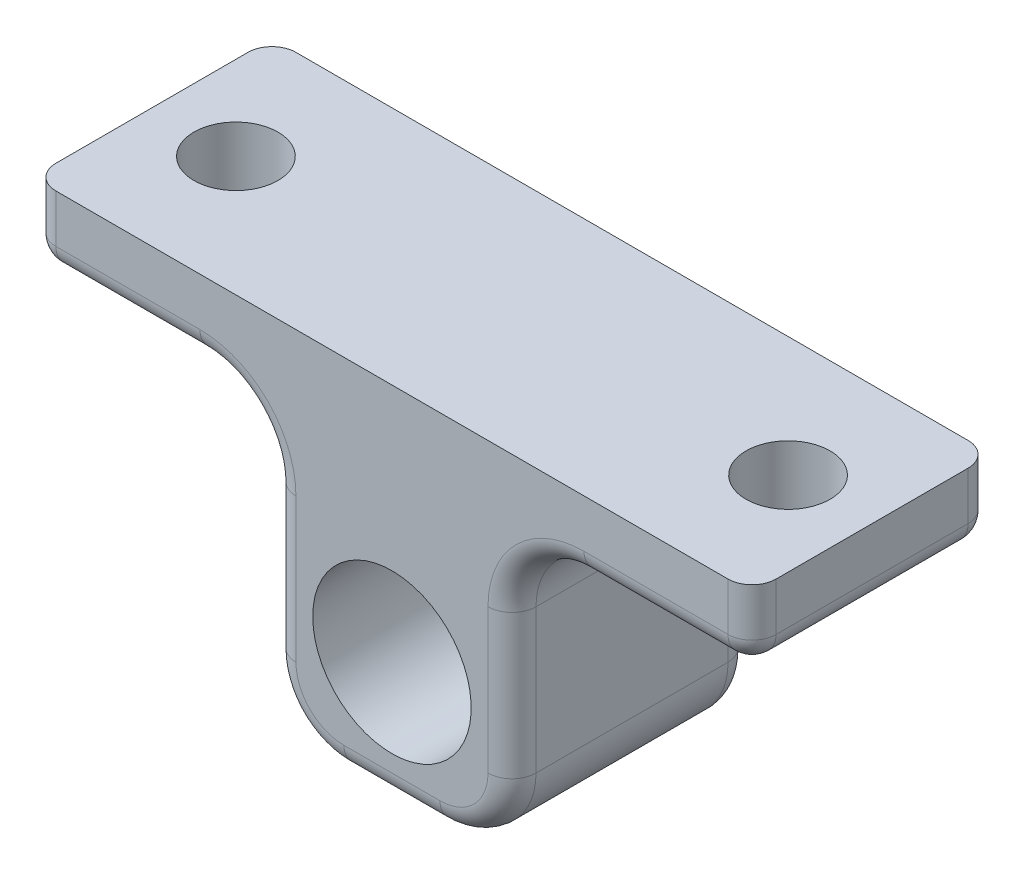
from build123d import *

# Parameters (mm, degrees)
SKETCH_1_W          = 10
SKETCH_1_H          = 3
EXTRUDE_1_DEPTH     = 10
SKETCH_2_R          = 3.3
CUT_EXTRUDE_1_DEPTH = 11
SKETCH_3_R          = 1.75
CUT_EXTRUDE_2_DEPTH = 4
FILLET_1_R          = 3
FILLET_2_R          = 1


with BuildPart() as part:
    # ｽｹｯﾁ1 → ﾎﾞｽ - 押し出し1 (new body)
    with BuildSketch(Plane.XY):
        Polygon((5, 10), (0, 10), (0, -5), (5, -5), (5, 7), align=None)
        with Locations((10, 8.5)):
            Rectangle(SKETCH_1_W, SKETCH_1_H)
        Polygon((0, -5), (0, 10), (-5, 10), (-5, 7), (-5, -5), align=None)
        with Locations((-10, 8.5)):
            Rectangle(SKETCH_1_W, SKETCH_1_H)
    extrude(amount=EXTRUDE_1_DEPTH)

    # ｽｹｯﾁ2 → ｶｯﾄ - 押し出し1 (cut, through all)
    with BuildSketch(Plane(origin=(0, 0, 0), x_dir=(-1, 0, 0), z_dir=(0, 0, -1))):
        Circle(SKETCH_2_R)
    extrude(amount=-CUT_EXTRUDE_1_DEPTH, mode=Mode.SUBTRACT)

    # ｽｹｯﾁ3 → ｶｯﾄ - 押し出し2 (cut, through all)
    with BuildSketch(Plane.XZ.offset(-7)):
        with Locations((-11.5, 5)):
            Circle(SKETCH_3_R)
        with Locations((11.5, 5)):
            Circle(SKETCH_3_R)
    extrude(amount=-CUT_EXTRUDE_2_DEPTH, mode=Mode.SUBTRACT)

    # ﾌｨﾚｯﾄ1
    fillet_1_edges = [part.edges().sort_by_distance(p)[0] for p in [
        (5, -5, 5),
        (-5, -5, 5),
        (-5, 7, 5),
        (5, 7, 5),
    ]]
    fillet(fillet_1_edges, radius=FILLET_1_R)

    # ﾌｨﾚｯﾄ2
    fillet_2_edges = [part.edges().sort_by_distance(p)[0] for p in [
        (-15, 8.5, 0),
        (15, 8.5, 0),
        (15, 8.5, 10),
        (-15, 7, 5),
        (15, 7, 5),
        (-15, 8.5, 10),
        (-5, 1, 0),
        (-5, 1, 10),
        (-11.5, 7, 0),
        (-11.5, 7, 10),
        (11.5, 7, 0),
        (11.5, 7, 10),
        (5, 1, 0),
        (5, 1, 10),
        (0, -5, 0),
        (0, -5, 10),
        (4.121320344, -4.121320344, 0),
        (-4.121320344, -4.121320344, 0),
        (4.121320344, -4.121320344, 10),
        (-4.121320344, -4.121320344, 10),
        (-5.878679656, 6.121320344, 0),
        (-5.878679656, 6.121320344, 10),
        (5.878679656, 6.121320344, 0),
        (5.878679656, 6.121320344, 10),
    ]]
    fillet(fillet_2_edges, radius=FILLET_2_R)


solid = part.part
